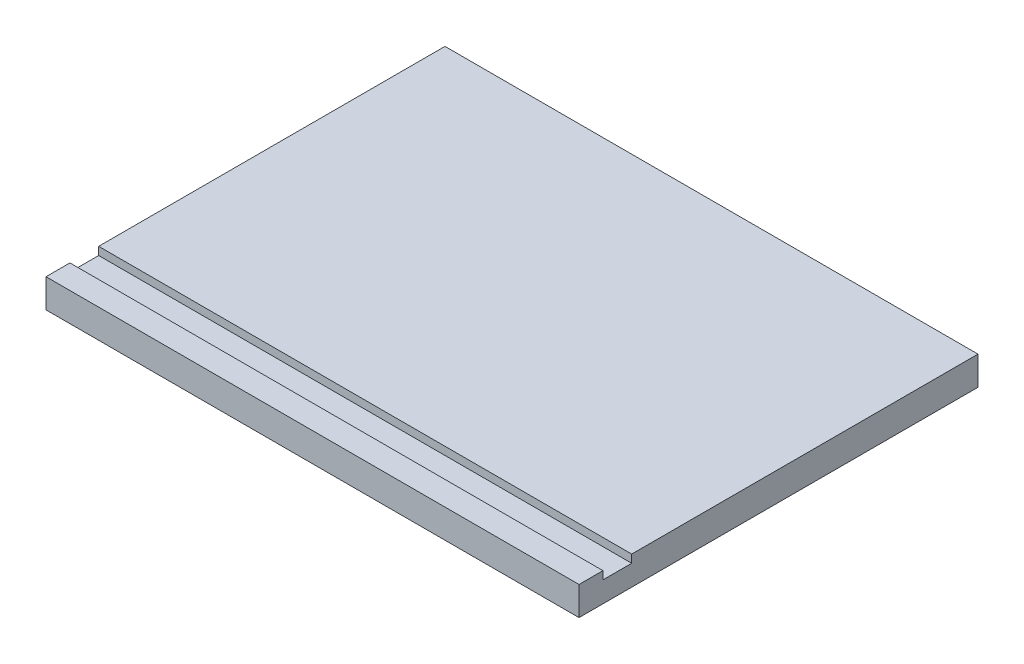
from build123d import *

# Parameters (mm, degrees)
SKETCH_1_W          = 334
SKETCH_1_H          = 250
EXTRUDE_1_DEPTH     = 18
SKETCH_2_W          = 334
SKETCH_2_H          = 18
CUT_EXTRUDE_1_DEPTH = 5


with BuildPart() as part:
    # Эскиз1 → Бобышка-Вытянуть1 (new body)
    with BuildSketch(Plane(origin=(0, 0, 0), x_dir=(1, 0, 0), z_dir=(0, 1, 0))):
        Rectangle(SKETCH_1_W, SKETCH_1_H)
    extrude(amount=EXTRUDE_1_DEPTH)

    # Эскиз2 → Вырез-Вытянуть1 (cut)
    with BuildSketch(Plane(origin=(0, 18, 0), x_dir=(1, 0, 0), z_dir=(0, 1, 0))):
        with Locations((0, -101)):
            Rectangle(SKETCH_2_W, SKETCH_2_H)
    extrude(amount=-CUT_EXTRUDE_1_DEPTH, mode=Mode.SUBTRACT)


solid = part.part
